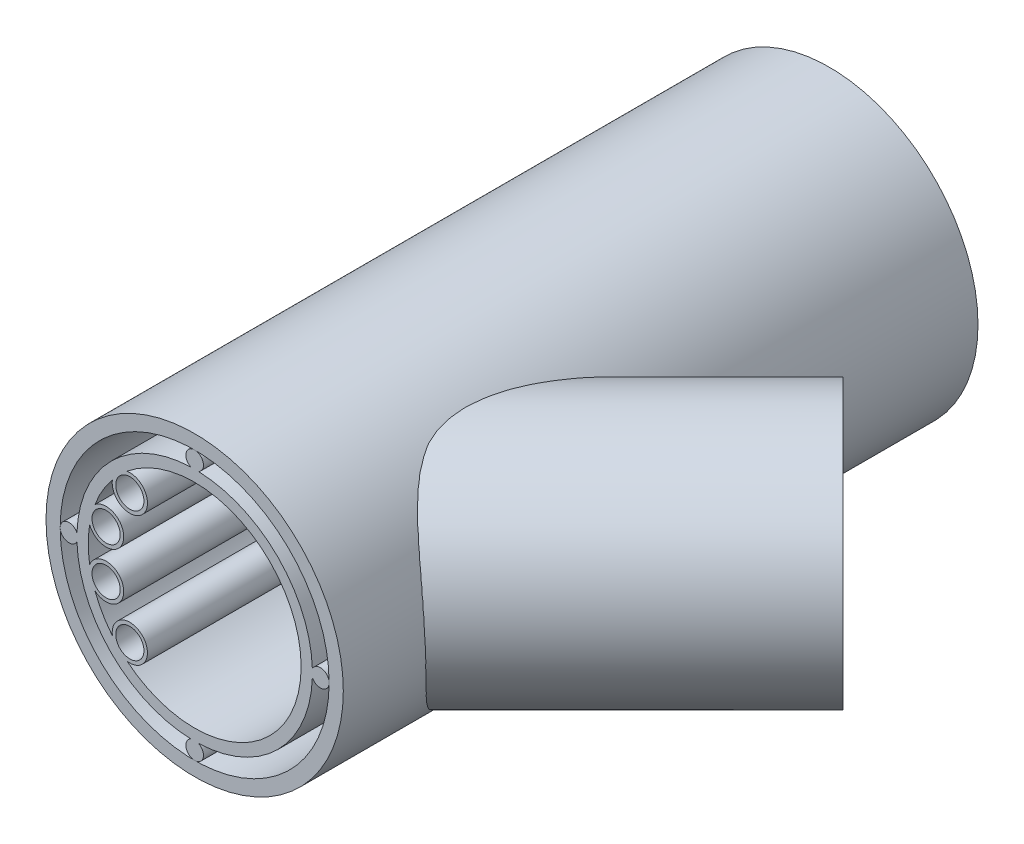
from build123d import *

# Parameters (mm, degrees)
SKETCH1_R           = 21.08
SKETCH1_R_2         = 19.07
BOSS_EXTRUDE1_DEPTH = 90
SKETCH3_R           = 16.7
SKETCH3_R_2         = 15.1
BOSS_EXTRUDE2_DEPTH = 90
SKETCH4_R           = 1.25
BOSS_EXTRUDE3_DEPTH = 90
SKETCH5_R           = 16.7
SKETCH5_R_2         = 15.1
BOSS_EXTRUDE8_DEPTH = 50
SKETCH6_R           = 15.1
CUT_EXTRUDE1_DEPTH  = 106.431717722
SKETCH7_R           = 15.1
CUT_EXTRUDE3_DEPTH  = 50
SKETCH8_R           = 2.5
SKETCH8_R_2         = 2
BOSS_EXTRUDE9_DEPTH = 90


with BuildPart() as part:
    # Sketch1 → Boss-Extrude1 (new body)
    with BuildSketch(Plane.XY):
        Circle(SKETCH1_R)
        Circle(SKETCH1_R_2, mode=Mode.SUBTRACT)
    extrude(amount=-BOSS_EXTRUDE1_DEPTH)


with BuildPart() as body_2:
    # Sketch3 → Boss-Extrude2 (new body)
    with BuildSketch(Plane.XY):
        Circle(SKETCH3_R)
        Circle(SKETCH3_R_2, mode=Mode.SUBTRACT)
    extrude(amount=-BOSS_EXTRUDE2_DEPTH)

    # Sketch4 → Boss-Extrude3 (add)
    with BuildSketch(Plane.XY):
        with Locations((0, -17.82)):
            Circle(SKETCH4_R)
        with Locations((-17.82, 0)):
            Circle(SKETCH4_R)
        with Locations((0, 17.82)):
            Circle(SKETCH4_R)
        with Locations((17.82, 0)):
            Circle(SKETCH4_R)
    extrude(amount=-BOSS_EXTRUDE3_DEPTH)


with BuildPart() as body_3:
    # Sketch5 → Boss-Extrude8 (new body)
    with BuildSketch(Plane(origin=(45.961940777, 0, -45.961940777), x_dir=(-0.7071067811865477, 0, -0.7071067811865475), z_dir=(0.7071067811865475, 0, -0.7071067811865477))):
        with Locations((9.985556521, 0.537271773)):
            Circle(SKETCH5_R)
        with Locations((9.985556521, 0.537271773)):
            Circle(SKETCH5_R_2, mode=Mode.SUBTRACT)
    extrude(amount=-BOSS_EXTRUDE8_DEPTH)

    # Sketch6 → Cut-Extrude1 (cut, through all)
    with BuildSketch(Plane.XY):
        Circle(SKETCH6_R)
    extrude(amount=-CUT_EXTRUDE1_DEPTH, mode=Mode.SUBTRACT)


with BuildPart() as cut_extrude3_tool:
    # Sketch7 → Cut-Extrude3 (new body)
    with BuildSketch(Plane(origin=(-82.071067812, 0, -173.994949366), x_dir=(0.7071067811865477, 0, 0.7071067811865475), z_dir=(-0.7071067811865475, 0, 0.7071067811865477))):
        with Locations(Location((171.080460657, 0.537271773, 0), (0, 0, 180))):
            Circle(SKETCH7_R)
    extrude(amount=CUT_EXTRUDE3_DEPTH)


with BuildPart() as part_1:
    add(part.part)

    # Cut-Extrude3: cut by cut_extrude3_tool
    add(cut_extrude3_tool.part, mode=Mode.SUBTRACT)


with BuildPart() as body_2_1:
    add(body_2.part)

    # Cut-Extrude3: cut by cut_extrude3_tool
    add(cut_extrude3_tool.part, mode=Mode.SUBTRACT)

    # Sketch8 → Boss-Extrude9 (add, through all)
    with BuildSketch(Plane.XY):
        with Locations((-9.192388155, -9.192388155)):
            Circle(SKETCH8_R)
        with Locations((-9.192388155, -9.192388155)):
            Circle(SKETCH8_R_2, mode=Mode.SUBTRACT)
        with Locations((-12.557035742, -3.364647586)):
            Circle(SKETCH8_R)
        with Locations((-12.557035742, -3.364647586)):
            Circle(SKETCH8_R_2, mode=Mode.SUBTRACT)
        with Locations((-12.557035742, 3.364647586)):
            Circle(SKETCH8_R)
        with Locations((-12.557035742, 3.364647586)):
            Circle(SKETCH8_R_2, mode=Mode.SUBTRACT)
        with Locations((-9.192388155, 9.192388155)):
            Circle(SKETCH8_R)
        with Locations((-9.192388155, 9.192388155)):
            Circle(SKETCH8_R_2, mode=Mode.SUBTRACT)
    extrude(amount=-BOSS_EXTRUDE9_DEPTH)


solid = Compound([body_3.part, part_1.part, body_2_1.part])
